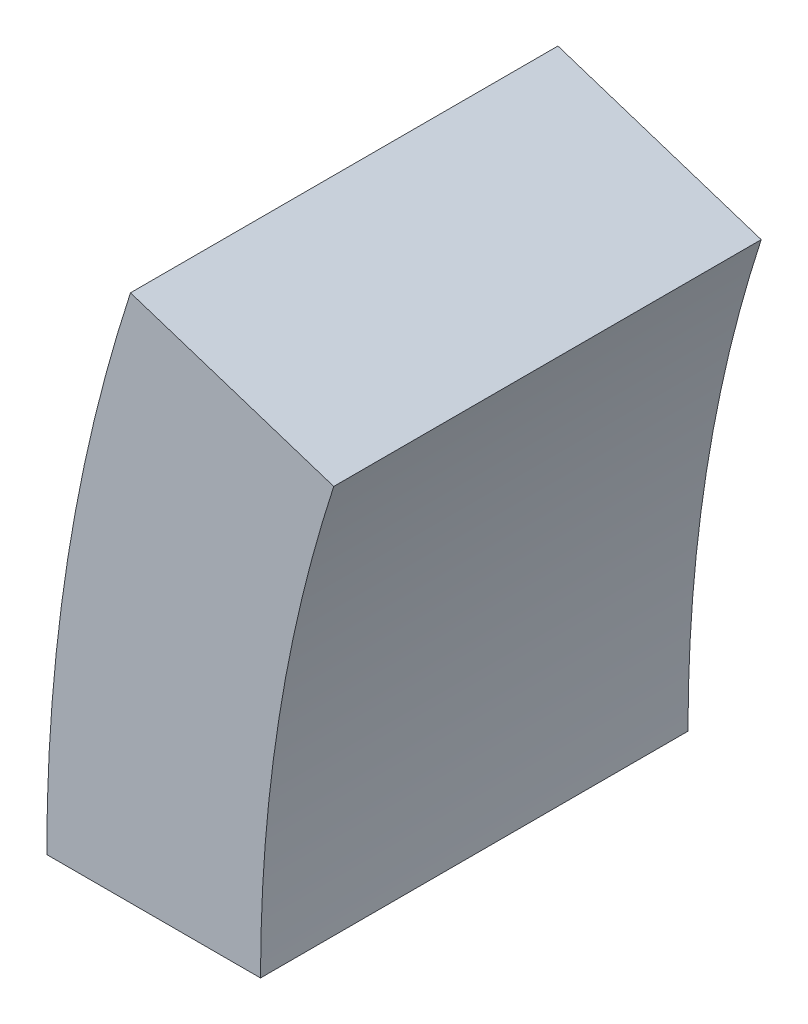
from build123d import *

# Parameters (mm, degrees)
EXTRUDE_1_DEPTH = 480
SCALE_1_SCALE   = 1.3


with BuildPart() as part:
    # 草图1 → 凸台-拉伸1 (new body)
    with BuildSketch(Plane.XY):
        with BuildLine():
            Line((-8160, 3840), (-7920, 3840))
            ThreePointArc((-7920, 3840), (-7899.3164122, 4102.809901268), (-7837.774947376, 4359.14855055))
            Line((-7837.774947376, 4359.14855055), (-8066.028511287, 4433.3126292))
            ThreePointArc((-8066.028511287, 4433.3126292), (-8091.25000196, 4349.188992657), (-8112.598195022, 4264))
            ThreePointArc((-8112.598195022, 4264), (-8148.112750133, 4053.320727495), (-8160, 3840))
        make_face()
    extrude(amount=EXTRUDE_1_DEPTH)


with BuildPart() as part_1:
    # 缩放比例1: scaled about (0, 0, 0)
    add(part.part.scale(SCALE_1_SCALE))


solid = part_1.part
